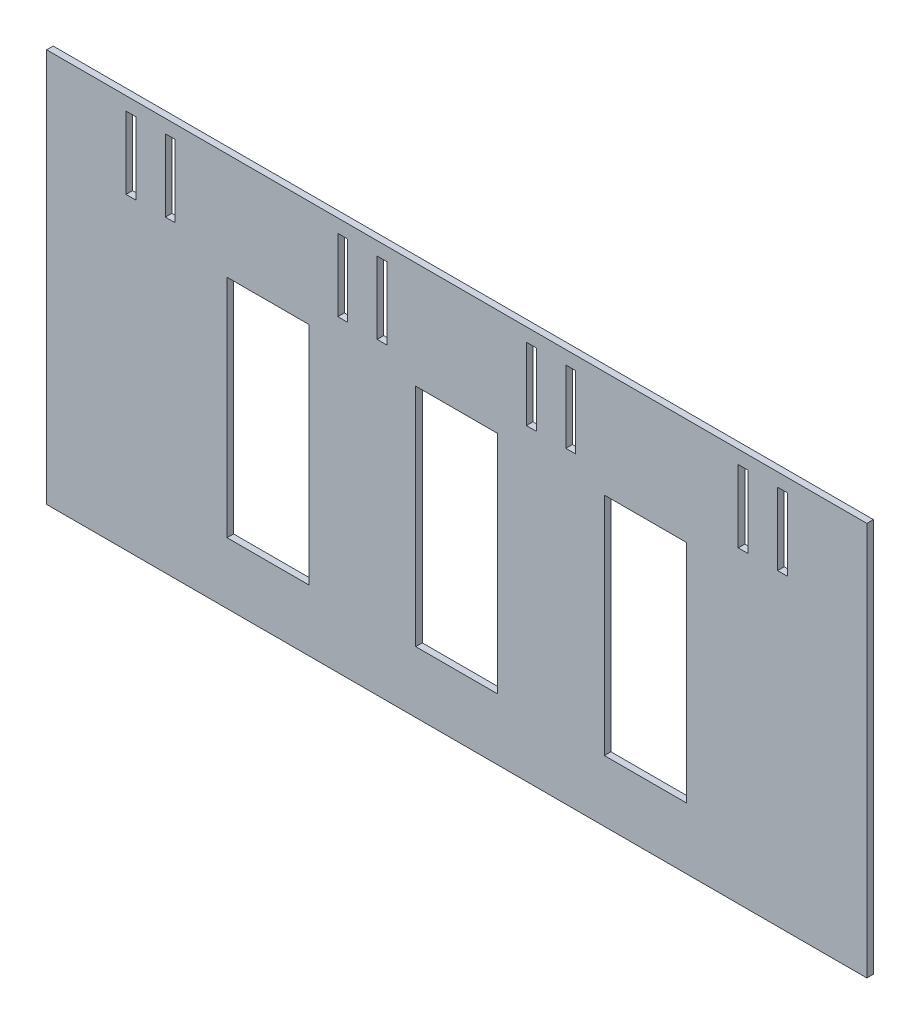
from build123d import *

# Parameters (mm, degrees)
SKETCH_1_W          = 250
SKETCH_1_H          = 120
EXTRUDE_1_DEPTH     = 2
SKETCH_2_W          = 3
SKETCH_2_H          = 22
CUT_EXTRUDE_1_DEPTH = 2
SKETCH_4_W          = 25
SKETCH_4_H          = 68.757414634
CUT_EXTRUDE_3_DEPTH = 10


with BuildPart() as part:
    # 草图1 → 凸台-拉伸1 (new body)
    with BuildSketch(Plane.XY):
        with Locations((85.581519181, 72.657914473)):
            Rectangle(SKETCH_1_W, SKETCH_1_H)
    extrude(amount=EXTRUDE_1_DEPTH)

    # 草图2 → 切除-拉伸1 (cut)
    with BuildSketch(Plane.XY.offset(2)):
        with Locations((-13.718480819, 117.592867426)):
            Rectangle(SKETCH_2_W, SKETCH_2_H)
        with Locations((-1.718480819, 117.592867426)):
            Rectangle(SKETCH_2_W, SKETCH_2_H)
        with Locations((50.831519181, 117.592867426)):
            Rectangle(SKETCH_2_W, SKETCH_2_H)
        with Locations((62.831519181, 117.592867426)):
            Rectangle(SKETCH_2_W, SKETCH_2_H)
        with Locations((108.331519181, 117.592867426)):
            Rectangle(SKETCH_2_W, SKETCH_2_H)
        with Locations((120.331519181, 117.592867426)):
            Rectangle(SKETCH_2_W, SKETCH_2_H)
        with Locations((172.881519181, 117.592867426)):
            Rectangle(SKETCH_2_W, SKETCH_2_H)
        with Locations((184.881519181, 117.592867426)):
            Rectangle(SKETCH_2_W, SKETCH_2_H)
    extrude(amount=-CUT_EXTRUDE_1_DEPTH, mode=Mode.SUBTRACT)

    # 草图4 → 切除-拉伸3 (cut)
    with BuildSketch(Plane(origin=(0, 0, 0), x_dir=(-1, 0, 0), z_dir=(0, 0, -1))):
        with Locations((-143.081519181, 65.748927638)):
            Rectangle(SKETCH_4_W, SKETCH_4_H)
        with Locations((-85.581519181, 65.748927638)):
            Rectangle(SKETCH_4_W, SKETCH_4_H)
        with Locations((-28.081519181, 65.748927638)):
            Rectangle(SKETCH_4_W, SKETCH_4_H)
    extrude(amount=-CUT_EXTRUDE_3_DEPTH, mode=Mode.SUBTRACT)


solid = part.part
